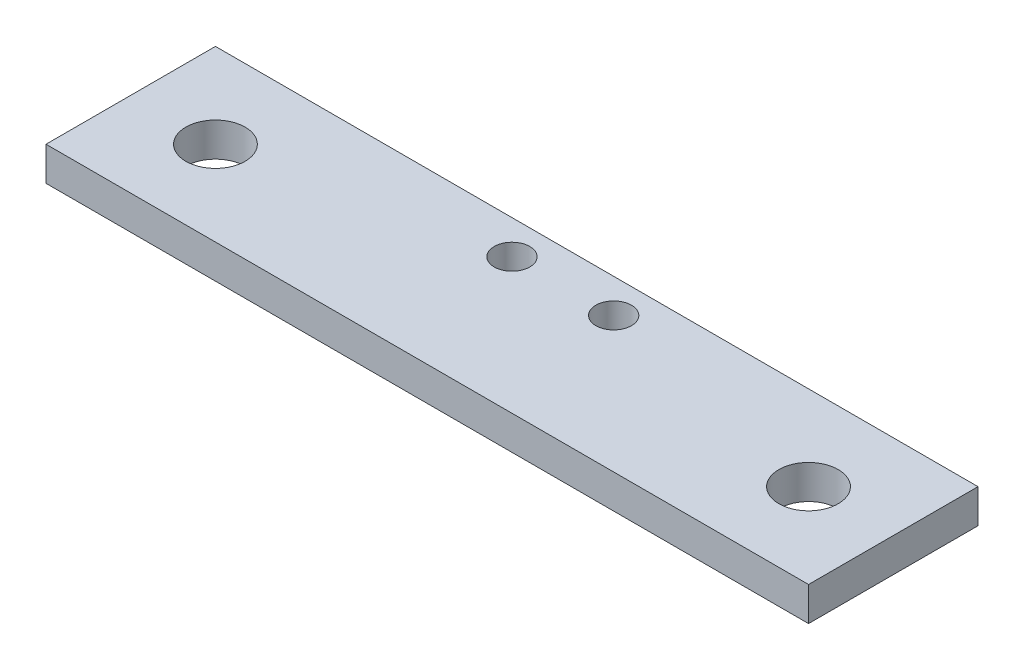
from build123d import *

# Parameters (mm, degrees)
SKETCH_1_W          = 90
SKETCH_1_H          = 20
EXTRUDE_1_DEPTH     = 4
SKETCH_2_R          = 3.5
SKETCH_2_R_2        = 2.1
CUT_EXTRUDE_1_DEPTH = 10


with BuildPart() as part:
    # 草图1 → 凸台-拉伸1 (new body)
    with BuildSketch(Plane(origin=(0, 0, 0), x_dir=(1, 0, 0), z_dir=(0, 1, 0))):
        Rectangle(SKETCH_1_W, SKETCH_1_H)
    extrude(amount=EXTRUDE_1_DEPTH)

    # 草图2 → 切除-拉伸1 (cut)
    with BuildSketch(Plane(origin=(0, 4, 0), x_dir=(1, 0, 0), z_dir=(0, 1, 0))):
        with Locations((-35, 0)):
            Circle(SKETCH_2_R)
        with Locations((35, 0)):
            Circle(SKETCH_2_R)
        with Locations((-6, 6)):
            Circle(SKETCH_2_R_2)
        with Locations((6, 6)):
            Circle(SKETCH_2_R_2)
    extrude(amount=-CUT_EXTRUDE_1_DEPTH, mode=Mode.SUBTRACT)


solid = part.part
